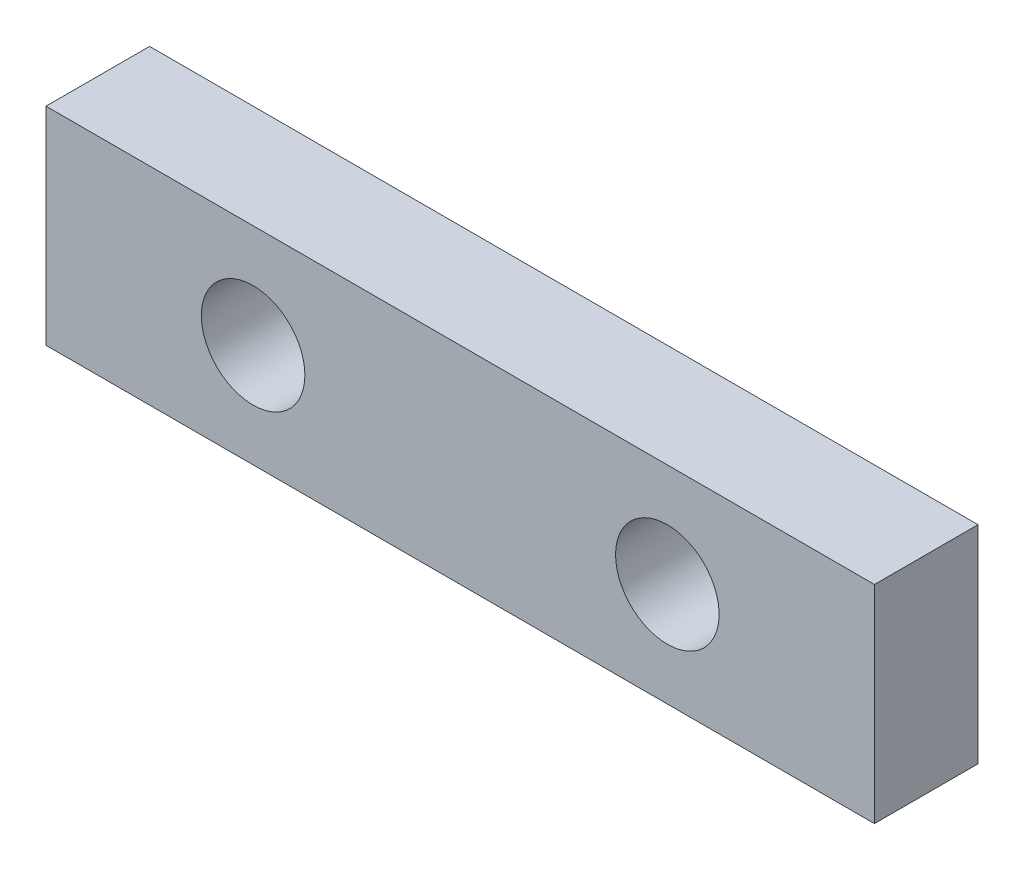
from build123d import *

# Parameters (mm, degrees)
SKETCH1_W           = 40
SKETCH1_H           = 10
SKETCH1_R           = 2.5
BOSS_EXTRUDE1_DEPTH = 5


with BuildPart() as part:
    # Sketch1 → Boss-Extrude1 (new body)
    with BuildSketch(Plane.XY):
        Rectangle(SKETCH1_W, SKETCH1_H)
        with Locations((-10, 0)):
            Circle(SKETCH1_R, mode=Mode.SUBTRACT)
        with Locations((10, 0)):
            Circle(SKETCH1_R, mode=Mode.SUBTRACT)
    extrude(amount=BOSS_EXTRUDE1_DEPTH)


solid = part.part
